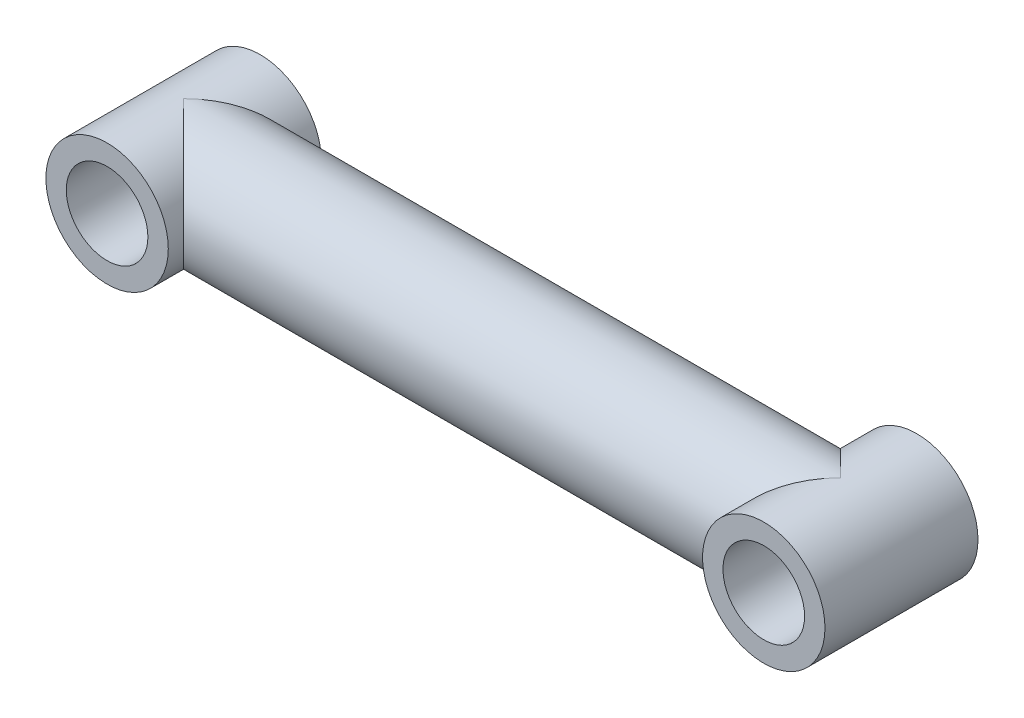
from build123d import *

# Parameters (mm, degrees)
BOSS_EXTRUDE1_DEPTH      = 25.9588
BOSS_EXTRUDE1_DEPTH_BACK = 25.9588
SKETCH1_R                = 4.8387
BOSS_EXTRUDE2_DEPTH      = 6.04901
BOSS_EXTRUDE2_DEPTH_BACK = 6.04901
SKETCH2_R                = 4.8387
SKETCH3_R                = 3.2258
CUT_EXTRUDE1_DEPTH       = 34.440411359


with BuildPart() as part:
    # Sketch1 → Boss-Extrude1 (new, two sides: drawn at the far end of the back side and taken through both)
    with BuildSketch(Plane(origin=(0, 0, 0), x_dir=(0, 0, -1), z_dir=(1, 0, 0)).offset(-BOSS_EXTRUDE1_DEPTH_BACK)):
        Circle(SKETCH1_R)
    extrude(amount=BOSS_EXTRUDE1_DEPTH + BOSS_EXTRUDE1_DEPTH_BACK)

    # Sketch2 → Boss-Extrude2 (add, two sides: drawn at the far end of the back side and taken through both)
    with BuildSketch(Plane.XY.offset(-BOSS_EXTRUDE2_DEPTH_BACK)):
        with Locations((25.9588, 0)):
            Circle(SKETCH2_R)
        with Locations((-25.9588, 0)):
            Circle(SKETCH2_R)
    extrude(amount=BOSS_EXTRUDE2_DEPTH + BOSS_EXTRUDE2_DEPTH_BACK)

    # Sketch3 → Cut-Extrude1 (cut, through all)
    with BuildSketch(Plane.XY.offset(6.04901)):
        with Locations((-25.9588, 0)):
            Circle(SKETCH3_R)
        with Locations((25.9588, 0)):
            Circle(SKETCH3_R)
    extrude(amount=-CUT_EXTRUDE1_DEPTH, mode=Mode.SUBTRACT)


solid = part.part
